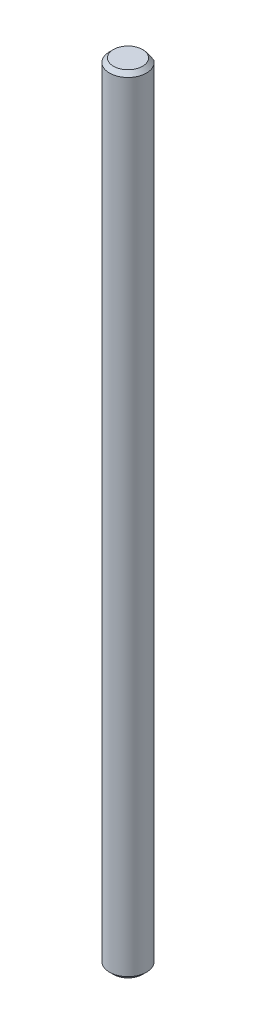
from build123d import *

# Parameters (mm, degrees)
CUT_EXTRUDE1_DEPTH = 101.055209759


with BuildPart() as part:
    # Sketch1 → Revolve1 (revolve)
    with BuildSketch(Plane.XY):
        Polygon((0, -50), (-1.85, -50), (-2.35, -49.5), (-2.35, 49.5), (-1.85, 50), (0, 50), align=None)
    revolve(axis=Axis((0, 50, 0), (0, -1, 0)))

    # Sketch2 → Cut-Extrude1 (cut, through all)
    with BuildSketch(Plane(origin=(0, 50, 0), x_dir=(1, 0, 0), z_dir=(0, 1, 0))):
        with BuildLine():
            ThreePointArc((1.42323575, 1.87), (0, 2.35), (-1.42323575, 1.87))
            Line((-1.42323575, 1.87), (1.42323575, 1.87))
        make_face()
    extrude(amount=-CUT_EXTRUDE1_DEPTH, mode=Mode.SUBTRACT)


solid = part.part
